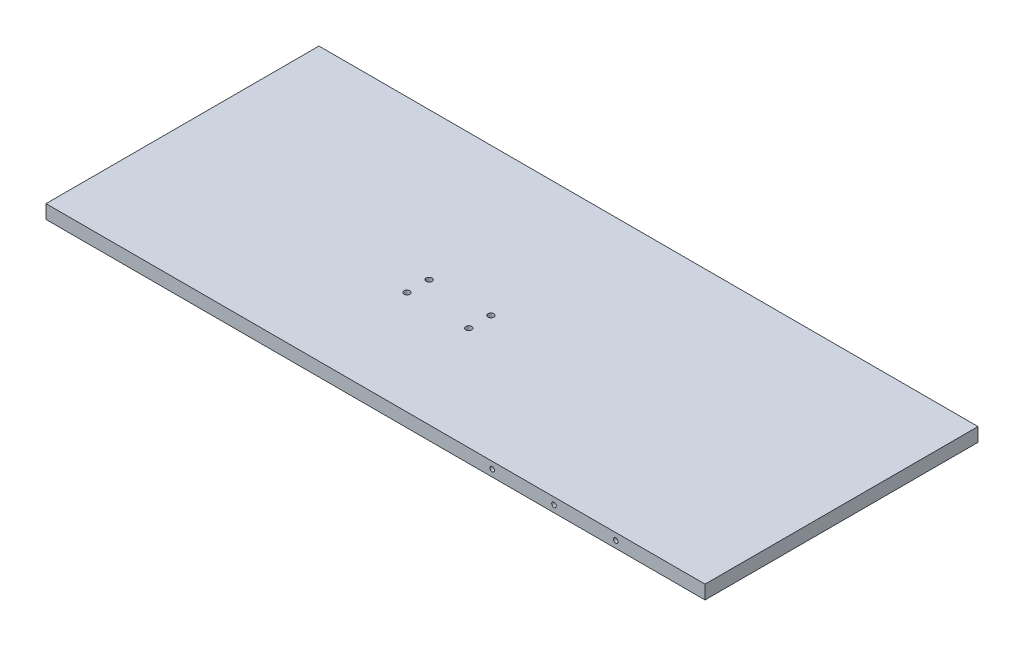
from build123d import *

# Parameters (mm, degrees)
SKETCH1_W                        = 1219.2
SKETCH1_H                        = 505
BOSS_EXTRUDE1_DEPTH              = 25.4
TAP_DRILL_FOR_M10X1_5_TAP1_D     = 8.5
TAP_DRILL_FOR_M10X1_5_TAP1_DEPTH = 20
TAP_DRILL_FOR_M10X1_5_TAP1_TIP   = 2.553657631
TAP_DRILL_FOR_M10X1_5_TAP2_D     = 8.5
TAP_DRILL_FOR_M10X1_5_TAP2_DEPTH = 20
TAP_DRILL_FOR_M10X1_5_TAP2_TIP   = 2.553657631
M10_CLEARANCE_HOLE1_D            = 11


with BuildPart() as part:
    # Sketch1 → Boss-Extrude1 (new body)
    with BuildSketch(Plane(origin=(0, 0, 0), x_dir=(1, 0, 0), z_dir=(0, 1, 0))):
        with Locations((-609.6, 252.5)):
            Rectangle(SKETCH1_W, SKETCH1_H)
    extrude(amount=BOSS_EXTRUDE1_DEPTH)

    # Tap Drill for M10x1.5 Tap1
    with Locations(Plane.XY):
        with Locations((-393.7, 12.7), (-279.4, 12.7), (-165.1, 12.7)):
            Hole(TAP_DRILL_FOR_M10X1_5_TAP1_D / 2, depth=TAP_DRILL_FOR_M10X1_5_TAP1_DEPTH)
            with Locations((0, 0, -(TAP_DRILL_FOR_M10X1_5_TAP1_DEPTH + TAP_DRILL_FOR_M10X1_5_TAP1_TIP / 2))):  # 118° drill point
                Cone(0, TAP_DRILL_FOR_M10X1_5_TAP1_D / 2, TAP_DRILL_FOR_M10X1_5_TAP1_TIP, mode=Mode.SUBTRACT)

    # Tap Drill for M10x1.5 Tap2
    with Locations(Plane(origin=(0, 0, -505), x_dir=(-1, 0, 0), z_dir=(0, 0, -1))):
        with Locations((165.1, 12.7), (279.4, 12.7), (393.7, 12.7)):
            Hole(TAP_DRILL_FOR_M10X1_5_TAP2_D / 2, depth=TAP_DRILL_FOR_M10X1_5_TAP2_DEPTH)
            with Locations((0, 0, -(TAP_DRILL_FOR_M10X1_5_TAP2_DEPTH + TAP_DRILL_FOR_M10X1_5_TAP2_TIP / 2))):  # 118° drill point
                Cone(0, TAP_DRILL_FOR_M10X1_5_TAP2_D / 2, TAP_DRILL_FOR_M10X1_5_TAP2_TIP, mode=Mode.SUBTRACT)

    # M10 Clearance Hole1 (through all)
    with Locations(Plane(origin=(0, 25.4, 0), x_dir=(1, 0, 0), z_dir=(0, 1, 0))):
        with Locations((-628.6, 191.6), (-628.6, 232.5), (-743, 232.5), (-743, 191.6)):
            Hole(M10_CLEARANCE_HOLE1_D / 2)


solid = part.part
